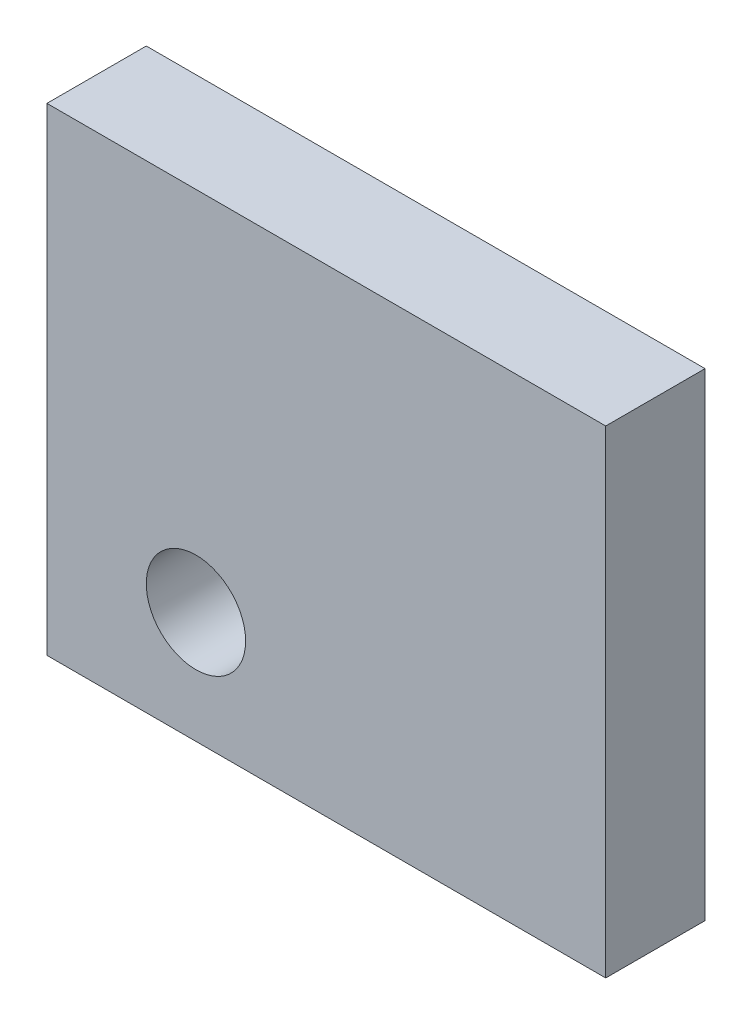
from build123d import *

# Parameters (mm, degrees)
SKETCH1_W           = 45
SKETCH1_H           = 38.5
BOSS_EXTRUDE1_DEPTH = 8
SKETCH2_R           = 4
CUT_EXTRUDE1_DEPTH  = 8


with BuildPart() as part:
    # Sketch1 → Boss-Extrude1 (new body)
    with BuildSketch(Plane.XY):
        with Locations((0, 5.75)):
            Rectangle(SKETCH1_W, SKETCH1_H)
    extrude(amount=BOSS_EXTRUDE1_DEPTH)

    # Sketch2 → Cut-Extrude1 (cut)
    with BuildSketch(Plane.XY.offset(8)):
        with Locations((-10.5, -4.5)):
            Circle(SKETCH2_R)
    extrude(amount=-CUT_EXTRUDE1_DEPTH, mode=Mode.SUBTRACT)


solid = part.part
